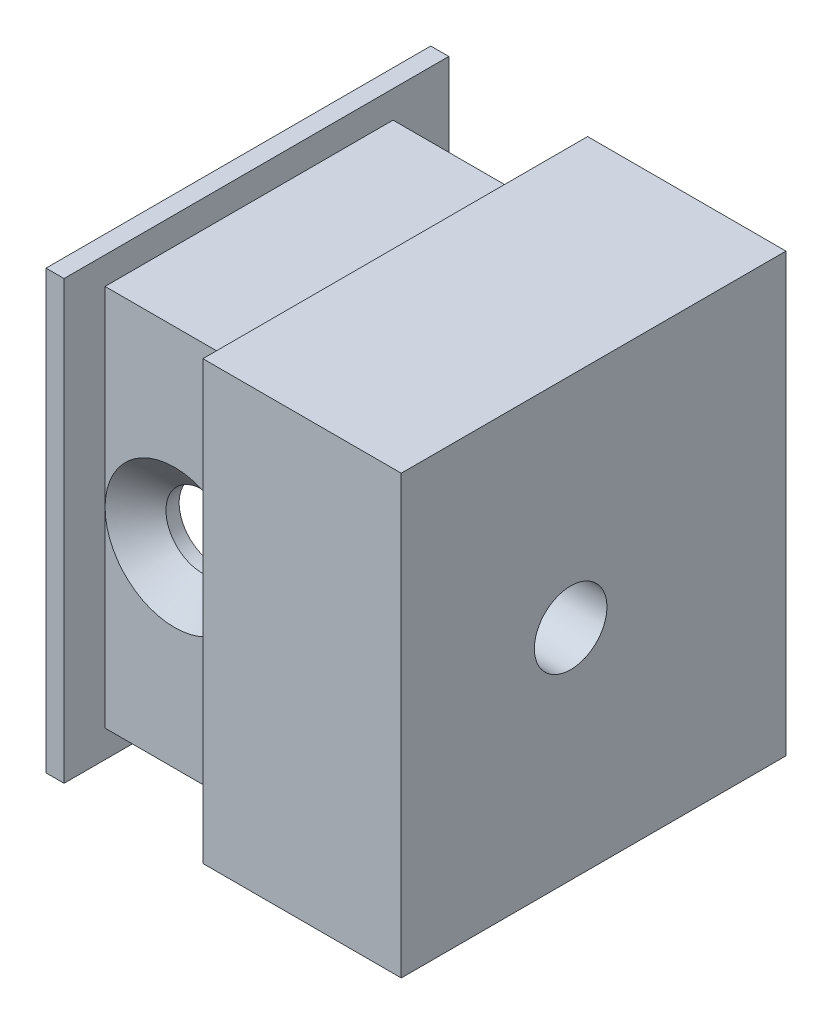
from build123d import *

# Parameters (mm, degrees)
BOSS_EXTRUDE1_DEPTH                 = 38.1
SKETCH2_W                           = 41.275
SKETCH2_H                           = 44.704
END_CAPS_DEPTH                      = 6.35
CHANNEL_COUNTERSINK_PRE_D           = 8.4328
CHANNEL_COUNTERSINK_PRE_DEPTH       = 9.525
CHANNEL_COUNTERSINK_PRE_CSINK_D     = 16.129
CHANNEL_COUNTERSINK_PRE_CSINK_ANGLE = 100
CHANNEL_COUNTERSINK_PRE_TIP         = 2.533468714
MOUNTING_COUNTERSINK_D              = 8.4328
MOUNTING_COUNTERSINK_CSINK_D        = 16.129
MOUNTING_COUNTERSINK_CSINK_ANGLE    = 100
SKETCH13_W                          = 16.129
SKETCH13_H                          = 4.7625
CHANNEL_TOP_AND_BOTTOM_DEPTH        = 51.8
CHANNEL_COUNTERSINK_D               = 8.4328
CHANNEL_COUNTERSINK_DEPTH           = 4.7625
CHANNEL_COUNTERSINK_CSINK_D         = 16.129
CHANNEL_COUNTERSINK_CSINK_ANGLE     = 100
CHANNEL_COUNTERSINK_TIP             = 2.533468714
SKETCH16_W                          = 16.129
SKETCH16_H                          = 3.175
CHANNEL_LEFT_RIGHT_DEPTH            = 45.704
SKETCH17_W                          = 16.129
SKETCH17_H                          = 6.477
CUT_EXTRUDE3_DEPTH                  = 51.8
F_5_16_0_47_DIAMETER_HOLE1_D        = 11.938
F_5_16_0_47_DIAMETER_HOLE1_DEPTH    = 14.859


with BuildPart() as part:
    # Sketch1 → Boss-Extrude1 (new body)
    with BuildSketch(Plane(origin=(0, 0, 0), x_dir=(1, 0, 0), z_dir=(0, 1, 0))):
        Polygon((0, 0), (-41.275, 0), (-41.275, -14.859), (-9.525, -14.859), (-9.525, -35.179), (-41.275, -35.179), (-41.275, -44.704), (0, -44.704), align=None)
    extrude(amount=BOSS_EXTRUDE1_DEPTH)

    # Sketch2 → End Caps (add)
    with BuildSketch(Plane(origin=(0, 38.1, 0), x_dir=(-1, 0, 0), z_dir=(0, 1, 0))):
        with Locations((20.6375, 22.352)):
            Rectangle(SKETCH2_W, SKETCH2_H)
    end_caps = extrude(amount=END_CAPS_DEPTH)

    # Mirror1: End Caps across plane
    add(end_caps.mirror(Plane(origin=(0, 19.05, 0), x_dir=(0, 0, 1), z_dir=(0, -1, 0))))

    # Channel Countersink-PRE
    with Locations(Plane.XY.offset(44.704)):
        with Locations((-31.115, 19.05)):
            CounterSinkHole(CHANNEL_COUNTERSINK_PRE_D / 2, CHANNEL_COUNTERSINK_PRE_CSINK_D / 2, depth=CHANNEL_COUNTERSINK_PRE_DEPTH, counter_sink_angle=CHANNEL_COUNTERSINK_PRE_CSINK_ANGLE)
            with Locations((0, 0, -(CHANNEL_COUNTERSINK_PRE_DEPTH + CHANNEL_COUNTERSINK_PRE_TIP / 2))):  # 118° drill point
                Cone(0, CHANNEL_COUNTERSINK_PRE_D / 2, CHANNEL_COUNTERSINK_PRE_TIP, mode=Mode.SUBTRACT)

    # Mounting Countersink (through all)
    with Locations(Plane.ZY.offset(9.525)):
        with Locations((25.019, 19.05)):
            CounterSinkHole(MOUNTING_COUNTERSINK_D / 2, MOUNTING_COUNTERSINK_CSINK_D / 2, counter_sink_angle=MOUNTING_COUNTERSINK_CSINK_ANGLE)

    # Sketch13 → Channel Top and Bottom (cut, through all)
    with BuildSketch(Plane.XZ.offset(6.35)):
        with Locations((-31.115, 42.32275)):
            Rectangle(SKETCH13_W, SKETCH13_H)
    extrude(amount=-CHANNEL_TOP_AND_BOTTOM_DEPTH, mode=Mode.SUBTRACT)

    # Channel Countersink
    with Locations(Plane.XY.offset(39.9415)):
        with Locations((-31.115, 19.05)):
            CounterSinkHole(CHANNEL_COUNTERSINK_D / 2, CHANNEL_COUNTERSINK_CSINK_D / 2, depth=CHANNEL_COUNTERSINK_DEPTH, counter_sink_angle=CHANNEL_COUNTERSINK_CSINK_ANGLE)
            with Locations((0, 0, -(CHANNEL_COUNTERSINK_DEPTH + CHANNEL_COUNTERSINK_TIP / 2))):  # 118° drill point
                Cone(0, CHANNEL_COUNTERSINK_D / 2, CHANNEL_COUNTERSINK_TIP, mode=Mode.SUBTRACT)

    # Sketch16 → Channel Left Right (cut, through all)
    with BuildSketch(Plane(origin=(0, 0, 0), x_dir=(1, 0, 0), z_dir=(0, 0, -1))):
        with Locations((-31.115, 4.7625)):
            Rectangle(SKETCH16_W, SKETCH16_H)
    channel_left_right = extrude(amount=-CHANNEL_LEFT_RIGHT_DEPTH, mode=Mode.SUBTRACT)

    # Sketch17 → Cut-Extrude3 (cut, through all)
    with BuildSketch(Plane(origin=(0, 44.45, 0), x_dir=(-1, 0, 0), z_dir=(0, 1, 0))):
        with Locations((31.115, 3.2385)):
            Rectangle(SKETCH17_W, SKETCH17_H)
    extrude(amount=-CUT_EXTRUDE3_DEPTH, mode=Mode.SUBTRACT)

    # Mirror3: Channel Left Right across plane
    add(channel_left_right.mirror(Plane(origin=(0, 19.05, 0), x_dir=(0, 0, 1), z_dir=(0, -1, 0))), mode=Mode.SUBTRACT)

    # 5_16 _0.47_ Diameter Hole1
    with Locations(Plane(origin=(0, 0, 0), x_dir=(1, 0, 0), z_dir=(0, 0, -1))):
        with Locations((-31.115, -19.05)):
            Hole(F_5_16_0_47_DIAMETER_HOLE1_D / 2, depth=F_5_16_0_47_DIAMETER_HOLE1_DEPTH)


solid = part.part
